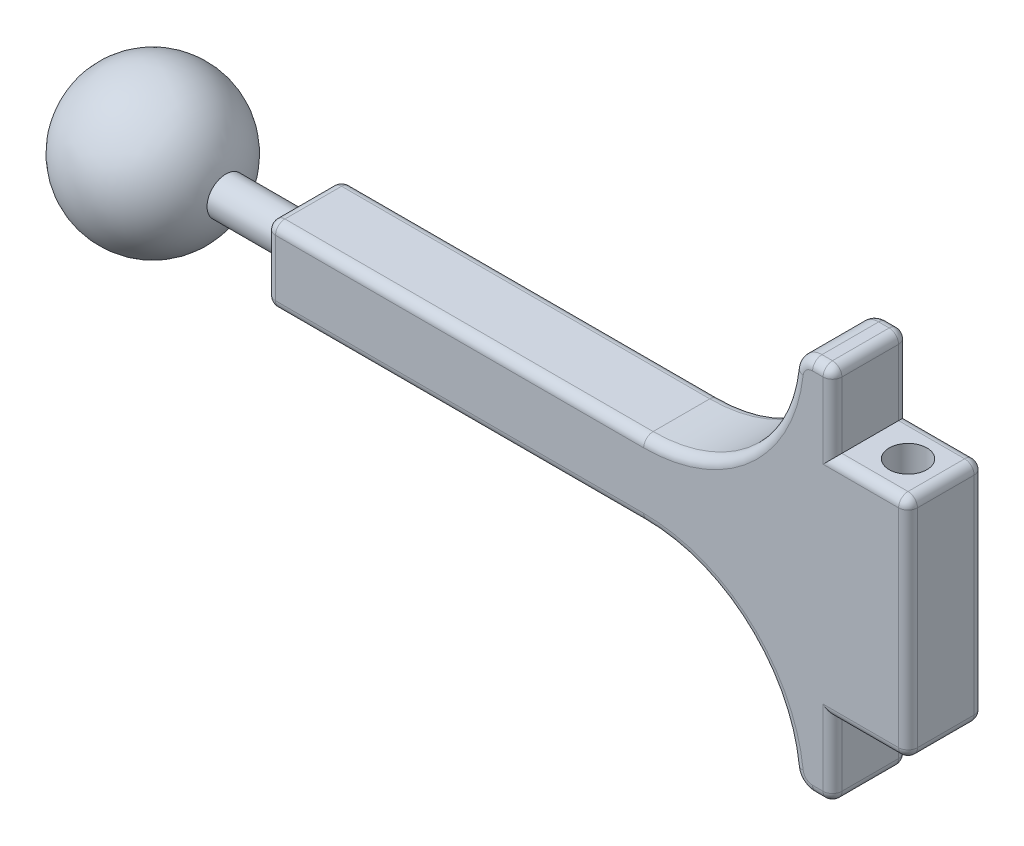
from build123d import *

# Parameters (mm, degrees)
BOSS_EXTRUDE2_DEPTH = 10
SKETCH2_R           = 2.5
BOSS_EXTRUDE3_DEPTH = 20
SKETCH4_R           = 2.5
CUT_EXTRUDE1_DEPTH  = 41
FILLET1_R           = 1.25


with BuildPart() as part:
    # Sketch1 → Boss-Extrude2 (new body)
    with BuildSketch(Plane.XY):
        with BuildLine():
            Line((-80, 5), (-30, 5))
            ThreePointArc((-30, 5), (-16.666666667, 10.09288015), (-10.1238402, 22.777777778))
            ThreePointArc((-10.1238402, 22.777777778), (-9.305986892, 24.363389981), (-7.639320225, 25))
            Line((-7.639320225, 25), (-5, 25))
            Line((-5, 25), (-5, 15))
            Line((-5, 15), (5, 15))
            Line((5, 15), (5, -15))
            Line((5, -15), (-5, -15))
            Line((-5, -15), (-5, -25))
            Line((-5, -25), (-7.639320225, -25))
            ThreePointArc((-7.639320225, -25), (-9.305986892, -24.363389981), (-10.1238402, -22.777777778))
            ThreePointArc((-10.1238402, -22.777777778), (-16.666666667, -10.09288015), (-30, -5))
            Line((-30, -5), (-80, -5))
            Line((-80, -5), (-80, 5))
        make_face()
    extrude(amount=BOSS_EXTRUDE2_DEPTH)

    # Sketch2 → Boss-Extrude3 (add)
    with BuildSketch(Plane.ZY.offset(80)):
        with Locations((5, 0)):
            Circle(SKETCH2_R)
    extrude(amount=BOSS_EXTRUDE3_DEPTH)

    # Sketch3 → Revolve1 (revolve)
    with BuildSketch(Plane.ZY.offset(100)):
        with BuildLine():
            Line((5, 10), (5, -10))
            ThreePointArc((5, -10), (-5, 0), (5, 10))
        make_face()
    revolve(axis=Axis((-100, 10, 5), (0, -1, 0)))

    # Sketch4 → Cut-Extrude1 (cut, through all)
    with BuildSketch(Plane(origin=(0, 15, 0), x_dir=(1, 0, 0), z_dir=(0, 1, 0))):
        with Locations((0, -5)):
            Circle(SKETCH4_R)
    extrude(amount=-CUT_EXTRUDE1_DEPTH, mode=Mode.SUBTRACT)

    # Fillet1
    fillet1_edges = [part.edges().sort_by_distance(p)[0] for p in [
        (-16.666666667, -10.09288015, 10),
        (-55, 5, 0),
        (-16.666666667, 10.09288015, 0),
        (-9.305986892, 24.363389981, 0),
        (-6.319660113, 25, 0),
        (-5, 20, 0),
        (0, 15, 0),
        (5, 0, 0),
        (0, -15, 0),
        (-9.305986892, -24.363389981, 10),
        (-5, -20, 0),
        (-6.319660113, -25, 0),
        (-9.305986892, -24.363389981, 0),
        (-16.666666667, -10.09288015, 0),
        (-55, -5, 0),
        (-80, 0, 0),
        (-6.319660113, -25, 10),
        (-80, 5, 5),
        (-5, 25, 5),
        (5, 15, 5),
        (5, -15, 5),
        (-5, -25, 5),
        (-5, -20, 10),
        (-80, -5, 5),
        (0, -15, 10),
        (5, 0, 10),
        (0, 15, 10),
        (-5, 20, 10),
        (-6.319660113, 25, 10),
        (-9.305986892, 24.363389981, 10),
        (-80, 0, 10),
        (-16.666666667, 10.09288015, 10),
        (-55, 5, 10),
        (-55, -5, 10),
    ]]
    fillet(fillet1_edges, radius=FILLET1_R)


solid = part.part
